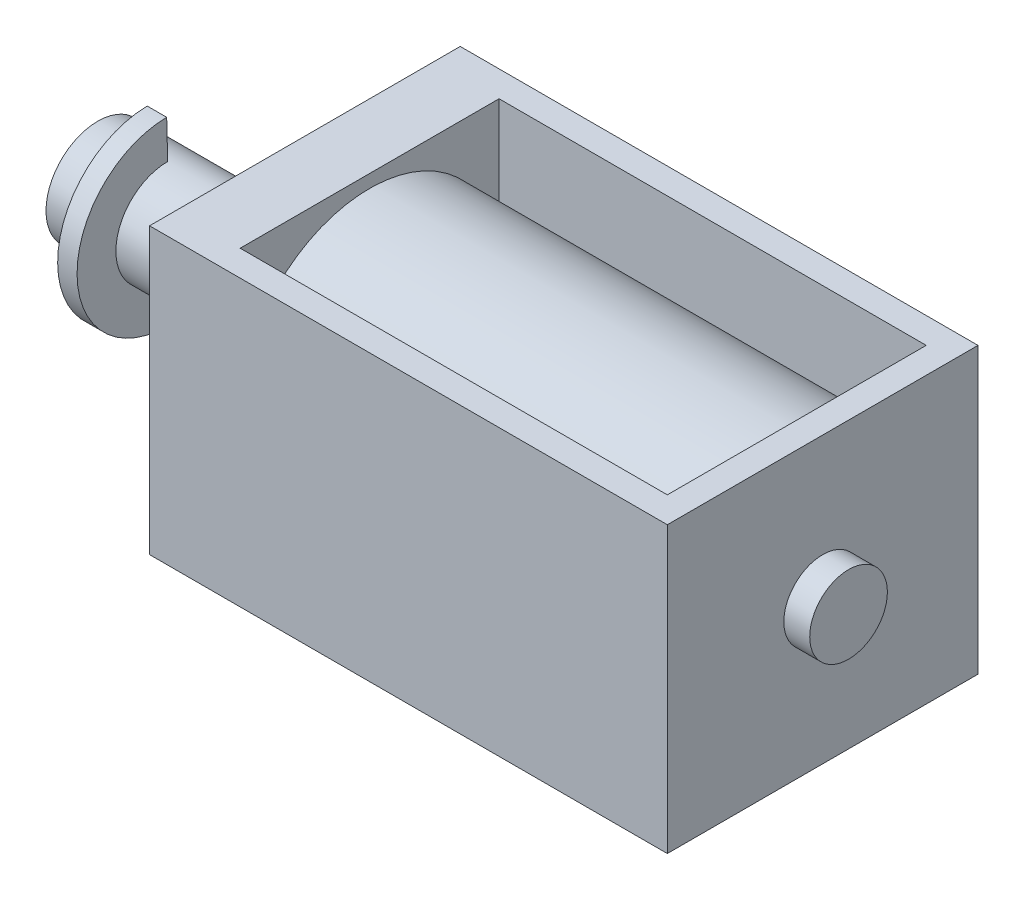
from build123d import *

# Parameters (mm, degrees)
SKETCH1_W           = 20
SKETCH1_H           = 12
BOSS_EXTRUDE1_DEPTH = 11
SKETCH3_W           = 16.5
SKETCH3_H           = 10
CUT_EXTRUDE1_DEPTH  = 12
BOSS_EXTRUDE3_REACH = 19.5
SKETCH4_R           = 5
SKETCH5_R           = 2
BOSS_EXTRUDE4_DEPTH = 8
SKETCH6_R           = 1.5
BOSS_EXTRUDE5_DEPTH = 1
BOSS_EXTRUDE6_DEPTH = 0.75


with BuildPart() as part:
    # Sketch1 → Boss-Extrude1 (new body)
    with BuildSketch(Plane(origin=(0, 0, 0), x_dir=(1, 0, 0), z_dir=(0, 1, 0))):
        with Locations((10, 6)):
            Rectangle(SKETCH1_W, SKETCH1_H)
    extrude(amount=BOSS_EXTRUDE1_DEPTH)

    # Sketch3 → Cut-Extrude1 (cut, through all)
    with BuildSketch(Plane(origin=(0, 11, 0), x_dir=(1, 0, 0), z_dir=(0, 1, 0))):
        with Locations((10.75, 6)):
            Rectangle(SKETCH3_W, SKETCH3_H)
    extrude(amount=-CUT_EXTRUDE1_DEPTH, mode=Mode.SUBTRACT)


with BuildPart() as body_2:

    # Sketch4 → Boss-Extrude3 (new body, up to next)
    with BuildSketch(Plane(origin=(2.5, 0, 0), x_dir=(0, 0, -1), z_dir=(1, 0, 0)), mode=Mode.PRIVATE) as boss_extrude3_sk1:
        with Locations((6, 5.5)):
            Circle(SKETCH4_R)
    boss_extrude3_tool1 = extrude(boss_extrude3_sk1.sketch, amount=BOSS_EXTRUDE3_REACH, mode=Mode.PRIVATE) - part.part
    add(boss_extrude3_tool1.solids().sort_by_distance((2.5, 5.5, -6))[0])


with BuildPart() as part_1:
    add(part.part)

    # Sketch5 → Boss-Extrude4 (add)
    with BuildSketch(Plane.ZY):
        with Locations((-6, 5.5)):
            Circle(SKETCH5_R)
    extrude(amount=BOSS_EXTRUDE4_DEPTH)

    # Sketch6 → Boss-Extrude5 (add)
    with BuildSketch(Plane(origin=(20, 0, 0), x_dir=(0, 0, -1), z_dir=(1, 0, 0))):
        with Locations((6, 5.5)):
            Circle(SKETCH6_R)
    extrude(amount=BOSS_EXTRUDE5_DEPTH)

    # Sketch7 → Boss-Extrude6 (add)
    with BuildSketch(Plane.ZY.offset(5.3)):
        with BuildLine():
            Line((-6, 7.5), (-5.961540784, 8.999788692))
            ThreePointArc((-5.961540784, 8.999788692), (-2.500052827, 5.480770102), (-6, 2))
            Line((-6, 2), (-6, 3.5))
            ThreePointArc((-6, 3.5), (-4, 5.5), (-6, 7.5))
        make_face()
    extrude(amount=BOSS_EXTRUDE6_DEPTH)


solid = Compound([body_2.part, part_1.part])
